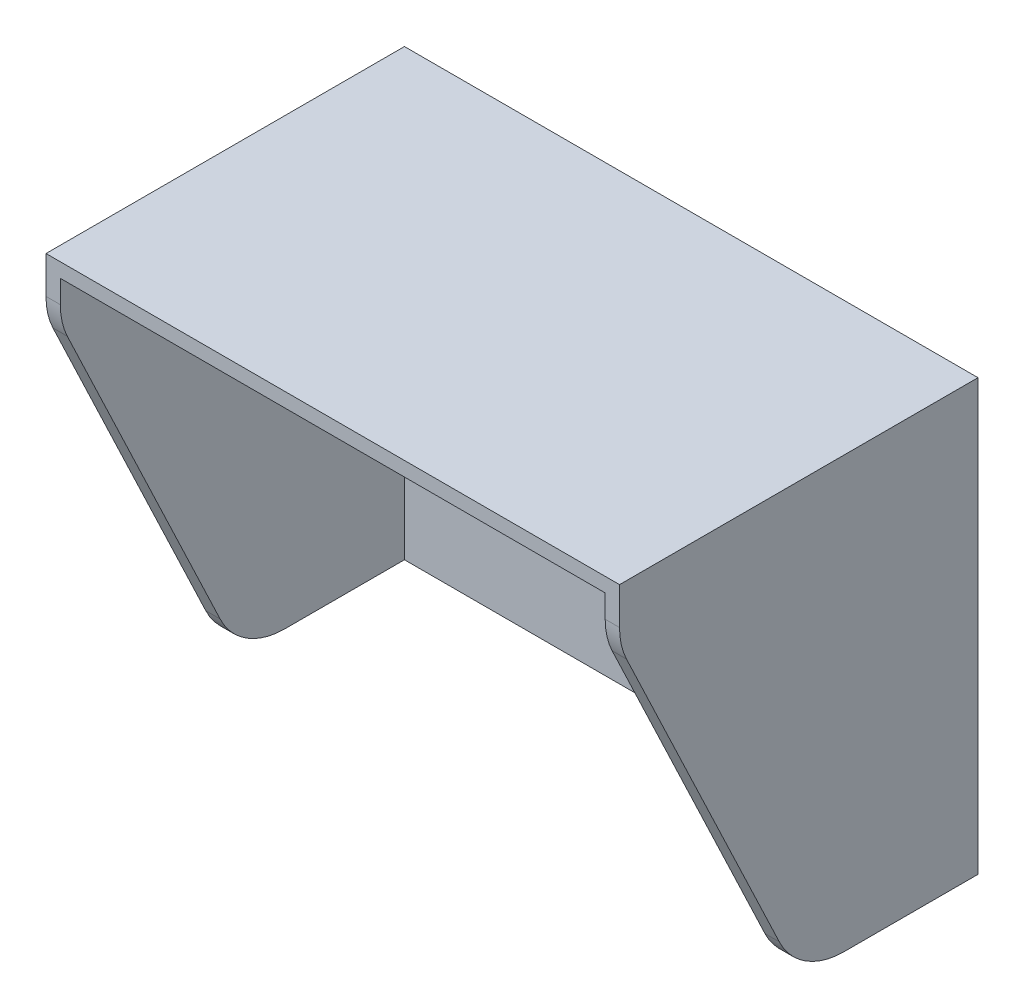
from build123d import *

# Parameters (mm, degrees)
SKETCH_1_W          = 80
SKETCH_1_H          = 60
SKETCH_1_R          = 1.6
EXTRUDE_1_DEPTH     = 50
SKETCH_2_W          = 76
SKETCH_2_H          = 58
CUT_EXTRUDE_1_DEPTH = 48
CUT_EXTRUDE_2_DEPTH = 81
FILLET_1_R          = 10


with BuildPart() as part:
    # 草图1 → 凸台-拉伸1 (new body)
    with BuildSketch(Plane.XY):
        with Locations((-8.993547962, 8.303805385)):
            Rectangle(SKETCH_1_W, SKETCH_1_H)
        with Locations((3.506452038, -1.696194615)):
            Circle(SKETCH_1_R, mode=Mode.SUBTRACT)
        with Locations((18.506452038, -1.696194615)):
            Circle(SKETCH_1_R, mode=Mode.SUBTRACT)
    extrude(amount=EXTRUDE_1_DEPTH)

    # 草图2 → 切除-拉伸1 (cut)
    with BuildSketch(Plane.XY.offset(50)):
        with Locations((-8.993547962, 7.303805385)):
            Rectangle(SKETCH_2_W, SKETCH_2_H)
    extrude(amount=-CUT_EXTRUDE_1_DEPTH, mode=Mode.SUBTRACT)

    # 草图3 → 切除-拉伸2 (cut, through all)
    with BuildSketch(Plane.ZY.offset(48.993547962)):
        Polygon((50, 30.864185465), (25, -21.696194615), (50, -21.696194615), align=None)
    extrude(amount=-CUT_EXTRUDE_2_DEPTH, mode=Mode.SUBTRACT)

    # 圆角1
    fillet_1_edges = [part.edges().sort_by_distance(p)[0] for p in [
        (-47.993547962, 30.864185465, 50),
        (30.006452038, 30.864185465, 50),
        (-47.993547962, -21.696194615, 25),
        (30.006452038, -21.696194615, 25),
    ]]
    fillet(fillet_1_edges, radius=FILLET_1_R)


solid = part.part
